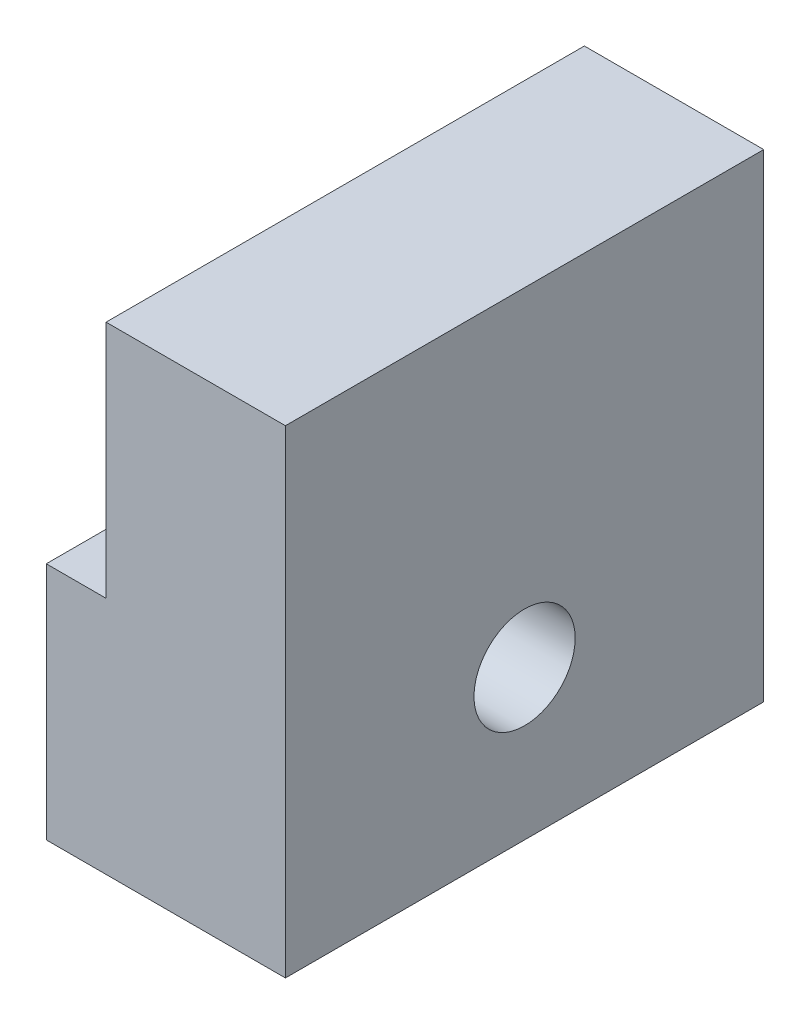
from build123d import *

# Parameters (mm, degrees)
SKETCH1_W           = 50.8
SKETCH1_H           = 50.8
SKETCH1_R           = 5.3721
BOSS_EXTRUDE1_DEPTH = 25.4
SKETCH2_W           = 50.8
SKETCH2_H           = 25.4
CUT_EXTRUDE1_DEPTH  = 6.35
SKETCH3_R           = 4.7625
CUT_EXTRUDE2_DEPTH  = 12.7


with BuildPart() as part:
    # Sketch1 → Boss-Extrude1 (new body)
    with BuildSketch(Plane(origin=(0, 0, 0), x_dir=(0, 0, -1), z_dir=(1, 0, 0))):
        Rectangle(SKETCH1_W, SKETCH1_H)
        with Locations((0, -9.525)):
            Circle(SKETCH1_R, mode=Mode.SUBTRACT)
    extrude(amount=BOSS_EXTRUDE1_DEPTH)

    # Sketch2 → Cut-Extrude1 (cut)
    with BuildSketch(Plane.ZY):
        with Locations((0, 12.7)):
            Rectangle(SKETCH2_W, SKETCH2_H)
    extrude(amount=-CUT_EXTRUDE1_DEPTH, mode=Mode.SUBTRACT)

    # Sketch3 → Cut-Extrude2 (cut)
    with BuildSketch(Plane.ZY.offset(-6.35)):
        with Locations((0, 12.7)):
            Circle(SKETCH3_R)
    extrude(amount=-CUT_EXTRUDE2_DEPTH, mode=Mode.SUBTRACT)


solid = part.part
